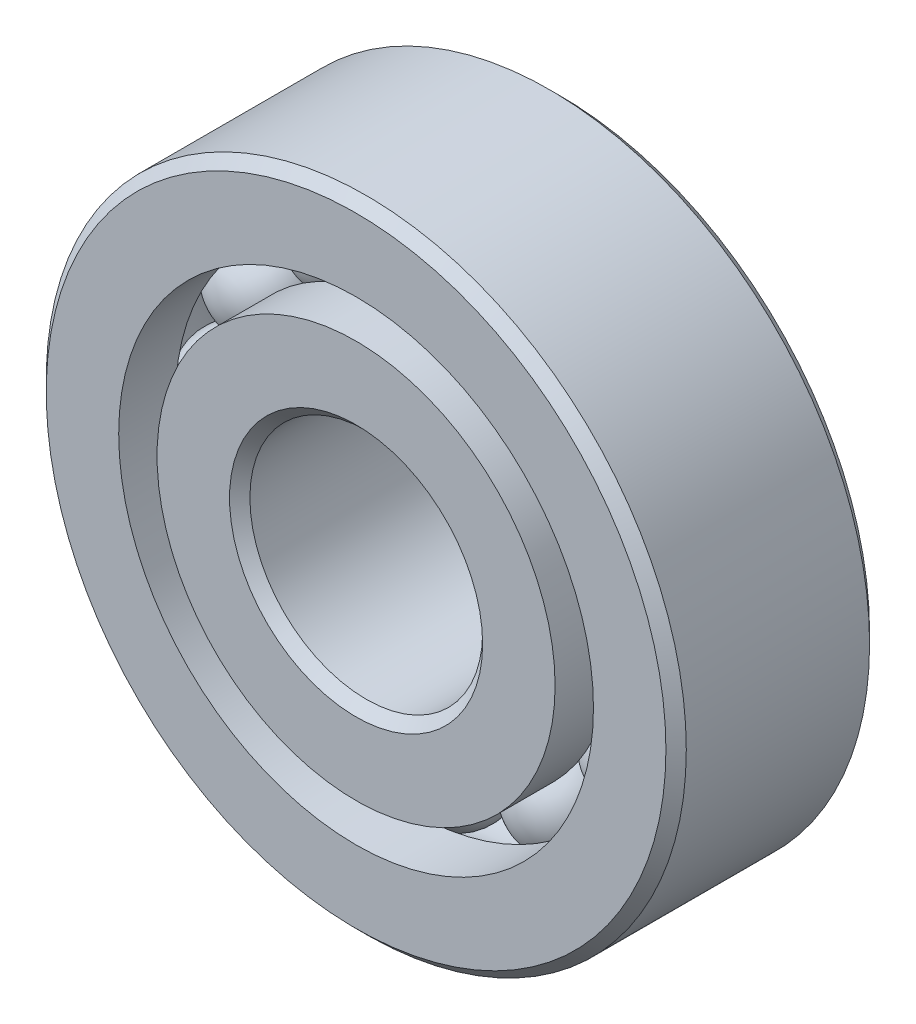
from build123d import *

# Parameters (mm, degrees)
CIRPATTERN1_COUNT = 12


with BuildPart() as part:
    # Sketch1 → Revolve1 (revolve)
    with BuildSketch(Plane(origin=(0, 0, 0), x_dir=(0, 0, -1), z_dir=(1, 0, 0))):
        with BuildLine():
            Line((3.15, 11), (-3.15, 11))
            Line((-3.15, 11), (-3.5, 10.65))
            Line((-3.5, 10.65), (-3.5, 8.159340659))
            Line((-3.5, 8.159340659), (-1.555555556, 8.159340659))
            ThreePointArc((-1.555555556, 8.159340659), (0, 9.189521587), (1.555555556, 8.159340659))
            Line((1.555555556, 8.159340659), (3.5, 8.159340659))
            Line((3.5, 8.159340659), (3.5, 10.65))
            Line((3.5, 10.65), (3.15, 11))
        make_face()
    revolve(axis=Axis((0, 0, 3.5), (0, 0, -1)))


with BuildPart() as body_2:
    # Sketch3 → Revolve3 (revolve)
    with BuildSketch(Plane(origin=(0, 0, 0), x_dir=(0, 0, -1), z_dir=(1, 0, 0))):
        with BuildLine():
            Line((-3.5, 6.840659341), (-1.555555556, 6.840659341))
            ThreePointArc((-1.555555556, 6.840659341), (0, 5.810478413), (1.555555556, 6.840659341))
            Line((1.555555556, 6.840659341), (3.5, 6.840659341))
            Line((3.5, 6.840659341), (3.5, 4.35))
            Line((3.5, 4.35), (3.15, 4))
            Line((3.15, 4), (-3.15, 4))
            Line((-3.15, 4), (-3.5, 4.35))
            Line((-3.5, 4.35), (-3.5, 6.840659341))
        make_face()
    revolve(axis=Axis((0, 0, 3.5), (0, 0, -1)))


with BuildPart() as body_3:
    # Sketch4 → Revolve4 (revolve)
    with BuildSketch(Plane(origin=(0, 0, 0), x_dir=(0, 0, -1), z_dir=(1, 0, 0))):
        with BuildLine():
            Line((-1.689521587, 7.5), (1.689521587, 7.5))
            ThreePointArc((1.689521587, 7.5), (0, 9.189521587), (-1.689521587, 7.5))
        make_face()
    revolve(axis=Axis((0, 7.5, 1.689521587), (0, 0, -1)))


with BuildPart() as cirpattern1_1:
    # CirPattern1: pattern copy
    add(body_3.part.rotate(Axis((0, 0, 0), (0, 0, 1)), 1 * 360 / CIRPATTERN1_COUNT))


with BuildPart() as cirpattern1_2:
    # CirPattern1: pattern copy
    add(body_3.part.rotate(Axis((0, 0, 0), (0, 0, 1)), 2 * 360 / CIRPATTERN1_COUNT))


with BuildPart() as cirpattern1_3:
    # CirPattern1: pattern copy
    add(body_3.part.rotate(Axis((0, 0, 0), (0, 0, 1)), 3 * 360 / CIRPATTERN1_COUNT))


with BuildPart() as cirpattern1_4:
    # CirPattern1: pattern copy
    add(body_3.part.rotate(Axis((0, 0, 0), (0, 0, 1)), 4 * 360 / CIRPATTERN1_COUNT))


with BuildPart() as cirpattern1_5:
    # CirPattern1: pattern copy
    add(body_3.part.rotate(Axis((0, 0, 0), (0, 0, 1)), 5 * 360 / CIRPATTERN1_COUNT))


with BuildPart() as cirpattern1_6:
    # CirPattern1: pattern copy
    add(body_3.part.rotate(Axis((0, 0, 0), (0, 0, 1)), 6 * 360 / CIRPATTERN1_COUNT))


with BuildPart() as cirpattern1_7:
    # CirPattern1: pattern copy
    add(body_3.part.rotate(Axis((0, 0, 0), (0, 0, 1)), 7 * 360 / CIRPATTERN1_COUNT))


with BuildPart() as cirpattern1_8:
    # CirPattern1: pattern copy
    add(body_3.part.rotate(Axis((0, 0, 0), (0, 0, 1)), 8 * 360 / CIRPATTERN1_COUNT))


with BuildPart() as cirpattern1_9:
    # CirPattern1: pattern copy
    add(body_3.part.rotate(Axis((0, 0, 0), (0, 0, 1)), 9 * 360 / CIRPATTERN1_COUNT))


with BuildPart() as cirpattern1_10:
    # CirPattern1: pattern copy
    add(body_3.part.rotate(Axis((0, 0, 0), (0, 0, 1)), 10 * 360 / CIRPATTERN1_COUNT))


with BuildPart() as cirpattern1_11:
    # CirPattern1: pattern copy
    add(body_3.part.rotate(Axis((0, 0, 0), (0, 0, 1)), 11 * 360 / CIRPATTERN1_COUNT))


solid = Compound([part.part, body_2.part, body_3.part, cirpattern1_1.part, cirpattern1_2.part, cirpattern1_3.part, cirpattern1_4.part, cirpattern1_5.part, cirpattern1_6.part, cirpattern1_7.part, cirpattern1_8.part, cirpattern1_9.part, cirpattern1_10.part, cirpattern1_11.part])
